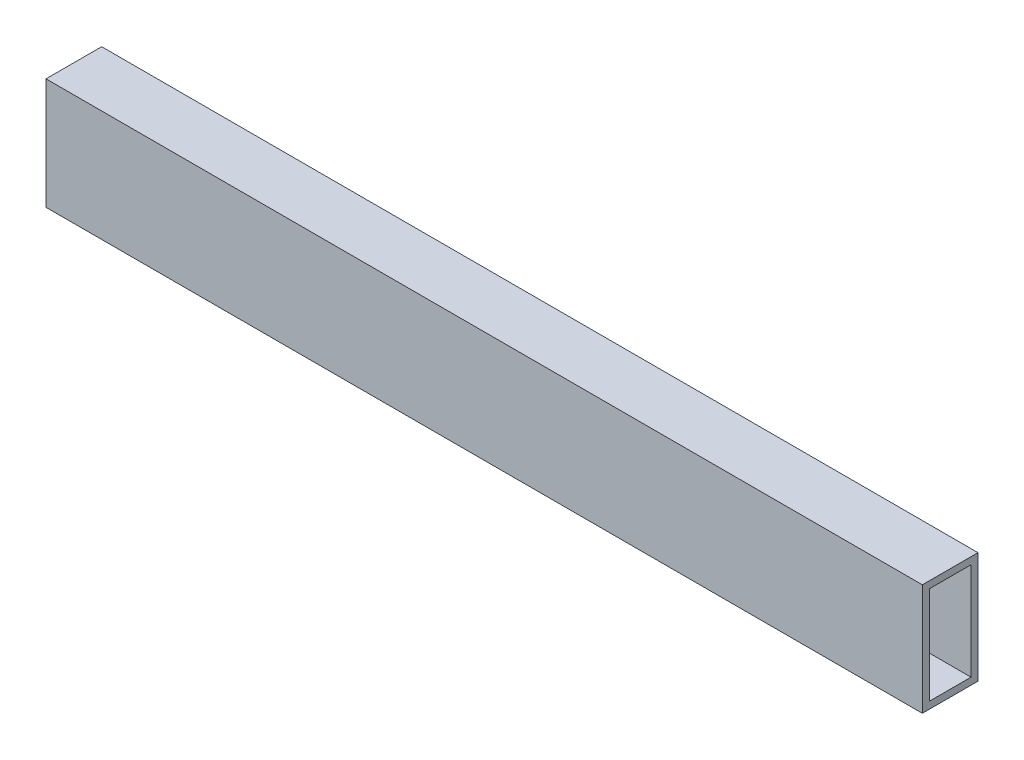
from build123d import *

# Parameters (mm, degrees)
SKETCH1_W           = 25.4
SKETCH1_H           = 50.8
SKETCH1_W_2         = 19.05
SKETCH1_H_2         = 44.45
BOSS_EXTRUDE1_DEPTH = 400


with BuildPart() as part:
    # Sketch1 → Boss-Extrude1 (new body)
    with BuildSketch(Plane(origin=(0, 0, 0), x_dir=(0, 0, -1), z_dir=(1, 0, 0))):
        with Locations((12.7, 25.4)):
            Rectangle(SKETCH1_W, SKETCH1_H)
        with Locations((12.7, 25.4)):
            Rectangle(SKETCH1_W_2, SKETCH1_H_2, mode=Mode.SUBTRACT)
    extrude(amount=BOSS_EXTRUDE1_DEPTH)


solid = part.part
